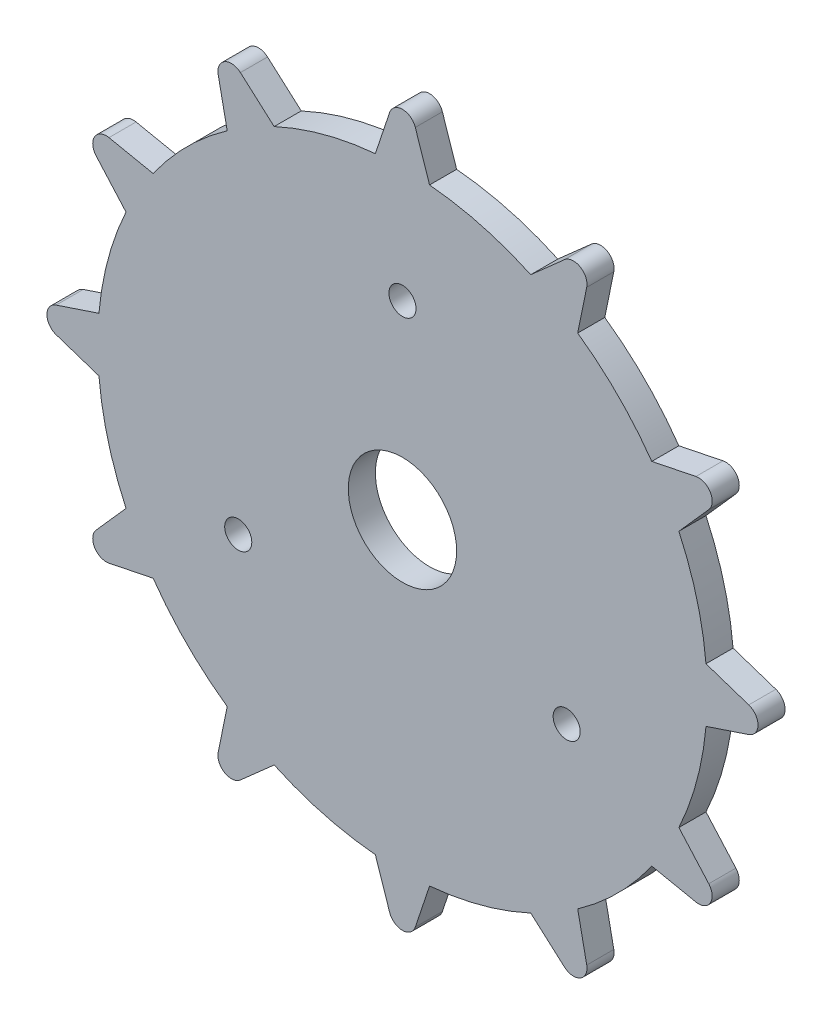
from build123d import *

# Parameters (mm, degrees)
SKETCH_1_R                       = 22.5
EXTRUDE_1_DEPTH                  = 2
EXTRUDE_2_DEPTH                  = 2
FILLET_1_R                       = 1
PATTERN_CIRCULAR_1_COUNT         = 12
FILLET_1_OF_PATTERN_CIRCULAR_1_R = 1
SKETCH_3_R                       = 4
CUT_EXTRUDE_1_DEPTH              = 2
SKETCH_4_R                       = 1
CUT_EXTRUDE_2_DEPTH              = 2
PATTERN_CIRCULAR_2_COUNT         = 3


with BuildPart() as part:
    # 草图1 → 凸台-拉伸1 (new body)
    with BuildSketch(Plane.XY):
        Circle(SKETCH_1_R)
    extrude(amount=EXTRUDE_1_DEPTH)

    # 草图2 → 凸台-拉伸2 (add)
    with BuildSketch(Plane.XY):
        with BuildLine():
            Line((0, 28.410934831), (-2.001953781, 22.410760386))
            ThreePointArc((-2.001953781, 22.410760386), (-0.000980777, 22.499999979), (2, 22.410934831))
            Line((2, 22.410934831), (0, 28.410934831))
        make_face()
    extrude_2 = extrude(amount=EXTRUDE_2_DEPTH)

    # 圆角1
    fillet_1_edges = [part.edges().sort_by_distance(p)[0] for p in [
        (0, 28.410934831, 1),
    ]]
    fillet(fillet_1_edges, radius=FILLET_1_R)

    # 阵列(圆周)1: 凸台-拉伸2 ×12 about axis
    pattern_circular_1_axis = Axis((0, 0, 0), (0, 0, 1))
    for i in range(1, PATTERN_CIRCULAR_1_COUNT):
        add(extrude_2.rotate(pattern_circular_1_axis, i * 360 / PATTERN_CIRCULAR_1_COUNT))

    # 圆角1 of 阵列(圆周)1
    fillet_1_of_pattern_circular_1_edges = [part.edges().sort_by_distance(p)[0] for p in [
        (-14.205467416, 24.604591309, 1),
        (-24.604591309, 14.205467416, 1),
        (-28.410934831, 0, 1),
        (-24.604591309, -14.205467416, 1),
        (-14.205467416, -24.604591309, 1),
        (0, -28.410934831, 1),
        (14.205467416, -24.604591309, 1),
        (24.604591309, -14.205467416, 1),
        (28.410934831, 0, 1),
        (24.604591309, 14.205467416, 1),
        (14.205467416, 24.604591309, 1),
    ]]
    fillet(fillet_1_of_pattern_circular_1_edges, radius=FILLET_1_OF_PATTERN_CIRCULAR_1_R)

    # 草图3 → 切除-拉伸1 (cut)
    with BuildSketch(Plane.XY.offset(2)):
        Circle(SKETCH_3_R)
    extrude(amount=-CUT_EXTRUDE_1_DEPTH, mode=Mode.SUBTRACT)

    # 草图4 → 切除-拉伸2 (cut)
    with BuildSketch(Plane.XY.offset(2)):
        with Locations((0, 14)):
            Circle(SKETCH_4_R)
    cut_extrude_2 = extrude(amount=-CUT_EXTRUDE_2_DEPTH, mode=Mode.SUBTRACT)

    # 阵列(圆周)2: 切除-拉伸2 ×3 about axis
    pattern_circular_2_axis = Axis((0, 0, 0), (0, 0, 1))
    for i in range(1, PATTERN_CIRCULAR_2_COUNT):
        add(cut_extrude_2.rotate(pattern_circular_2_axis, i * 360 / PATTERN_CIRCULAR_2_COUNT), mode=Mode.SUBTRACT)


solid = part.part
